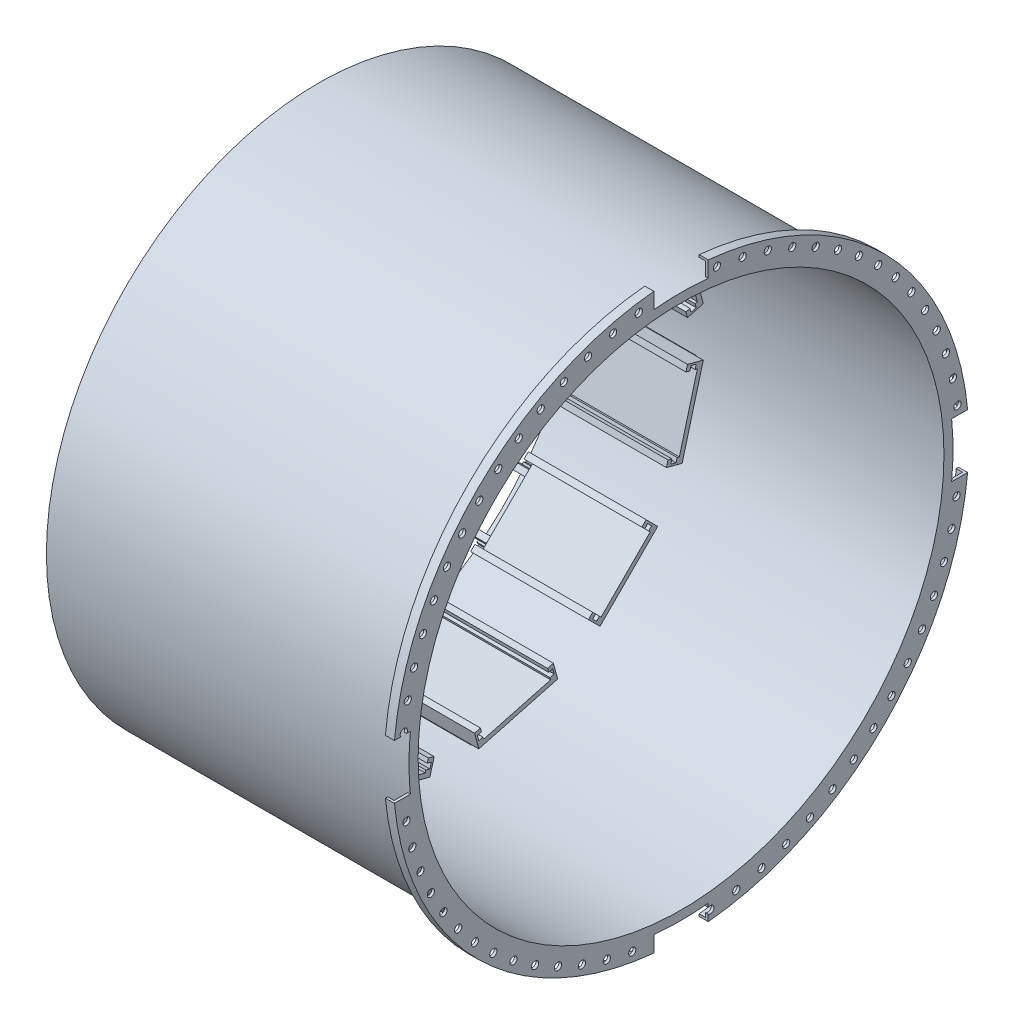
from build123d import *
from build123d.topology import SkipClean

# Parameters (mm, degrees)
CUT_EXTRUDE1_DEPTH    = 602.34224864
CIRPATTERN1_COUNT     = 4
BOSS_EXTRUDE1_DEPTH   = 130
BOSS_EXTRUDE2_DEPTH   = 130
BOSS_EXTRUDE2_2_DEPTH = 130
CIRPATTERN9_COUNT     = 12
SKETCH5_R             = 4
CUT_EXTRUDE2_DEPTH    = 130
CIRPATTERN10_COUNT    = 67


with BuildPart() as part:
    # Sketch1 → Revolve1 (revolve)
    with BuildSketch(Plane.XY, mode=Mode.PRIVATE) as revolve1_sk:
        Polygon((0, 290), (400, 290), (400, 317.5), (390, 317.5), (390, 315), (397, 315), (397, 300), (0, 300), align=None)
    revolve(revolve1_sk.sketch.rotate(Axis((-194.314172166, 0, 0), (1, 0, 0)), 90), axis=Axis((-194.314172166, 0, 0), (1, 0, 0)))

    # Sketch2 → Cut-Extrude1 (cut, through all)
    with SkipClean():  # the faces are left unmerged after this step: merging them gives an invalid solid
        with BuildSketch(Plane(origin=(0, 0, 0), x_dir=(0, 0, -1), z_dir=(1, 0, 0))):
            with BuildLine():
                Line((316.079499493, 30), (298.496231132, 30))
                ThreePointArc((298.496231132, 30), (300, 0), (298.496231132, -30))
                Line((298.496231132, -30), (316.079499493, -30))
                ThreePointArc((316.079499493, -30), (317.5, 0), (316.079499493, 30))
            make_face()
            with BuildLine():
                Line((-298.496231132, 30), (-316.079499493, 30))
                ThreePointArc((-316.079499493, 30), (-317.5, 0), (-316.079499493, -30))
                Line((-316.079499493, -30), (-298.496231132, -30))
                ThreePointArc((-298.496231132, -30), (-300, 0), (-298.496231132, 30))
            make_face()
        cut_extrude1 = extrude(amount=CUT_EXTRUDE1_DEPTH, mode=Mode.SUBTRACT)

    # CirPattern1: Cut-Extrude1 ×4 about axis
    with SkipClean():  # the faces are left unmerged after this step: merging them gives an invalid solid
        cirpattern1_axis = Axis((0, 0, 0), (-1, 0, 0))
        for i in range(1, CIRPATTERN1_COUNT):
            add(cut_extrude1.rotate(cirpattern1_axis, i * 360 / CIRPATTERN1_COUNT), mode=Mode.SUBTRACT)

    # Sketch5 → Cut-Extrude2 (cut)
    with SkipClean():  # the faces are left unmerged after this step: merging them gives an invalid solid
        with BuildSketch(Plane(origin=(400, 0, 0), x_dir=(0, 0, -1), z_dir=(1, 0, 0))):
            with Locations((217.435335215, 217.435335215)):
                Circle(SKETCH5_R)
        cut_extrude2 = extrude(amount=-CUT_EXTRUDE2_DEPTH, mode=Mode.SUBTRACT)

    # CirPattern10: Cut-Extrude2 ×67 about axis
    with SkipClean():  # the faces are left unmerged after this step: merging them gives an invalid solid
        cirpattern10_axis = Axis((0, 0, 0), (1, 0, 0))
        for i in range(1, CIRPATTERN10_COUNT):
            add(cut_extrude2.rotate(cirpattern10_axis, i * 360 / CIRPATTERN10_COUNT), mode=Mode.SUBTRACT)


with BuildPart() as body_2:
    # Sketch3 → Boss-Extrude1 (new body)
    with BuildSketch(Plane(origin=(20, 0, 0), x_dir=(0, 0, -1), z_dir=(1, 0, 0))):
        Polygon((-26.974606104, 274.537249226), (-113.90793047, 251.243535167), (-109.249187658, 233.856870294), (-102.832542394, 235.576205211), (-103.997228097, 239.922871429), (-108.482021709, 238.721174602), (-110.034935979, 244.51672956), (-105.550142368, 245.718426387), (-106.19718998, 248.133240952), (-32.097156143, 267.988285178), (-31.45010853, 265.573470613), (-26.965314918, 266.775167439), (-25.412400648, 260.979612481), (-29.897194259, 259.777915655), (-28.732508556, 255.431249437), (-22.315863292, 257.150584353), align=None)
    extrude(amount=BOSS_EXTRUDE1_DEPTH)


with BuildPart() as body_3:
    # Sketch4 → Boss-Extrude2 (new body)
    with BuildSketch(Plane(origin=(0, 0, 0), x_dir=(0, 0, -1), z_dir=(1, 0, 0))):
        Polygon((-38.357, 282.987347016), (-43, 282.987347016), (-43, 274.987347016), (-38.357, 274.987347016), (-38.357, 271.487347016), (-45, 271.487347016), (-45, 286.487347016), (-38.357, 286.487347016), align=None)
    extrude(amount=BOSS_EXTRUDE2_DEPTH)


with BuildPart() as body_4:
    # Sketch4 → Boss-Extrude2 2 (new body)
    with BuildSketch(Plane(origin=(0, 0, 0), x_dir=(0, 0, -1), z_dir=(1, 0, 0))):
        Polygon((-102.525537094, 254.293439321), (-96.77253034, 257.614939319), (-104.27253034, 270.605320376), (-110.025537095, 267.283820378), (-108.275537095, 264.252731465), (-104.254581145, 266.574231465), (-100.254581145, 259.646028235), (-104.275537095, 257.324528235), align=None)
    extrude(amount=BOSS_EXTRUDE2_2_DEPTH)


with BuildPart() as cirpattern9_1:
    # CirPattern9: pattern copy
    add(body_2.part.rotate(Axis((0, 0, 0), (1, 0, 0)), 1 * 360 / CIRPATTERN9_COUNT))


with BuildPart() as cirpattern9_2:
    # CirPattern9: pattern copy
    add(body_2.part.rotate(Axis((0, 0, 0), (1, 0, 0)), 2 * 360 / CIRPATTERN9_COUNT))


with BuildPart() as cirpattern9_3:
    # CirPattern9: pattern copy
    add(body_2.part.rotate(Axis((0, 0, 0), (1, 0, 0)), 3 * 360 / CIRPATTERN9_COUNT))


with BuildPart() as cirpattern9_4:
    # CirPattern9: pattern copy
    add(body_2.part.rotate(Axis((0, 0, 0), (1, 0, 0)), 4 * 360 / CIRPATTERN9_COUNT))


with BuildPart() as cirpattern9_5:
    # CirPattern9: pattern copy
    add(body_2.part.rotate(Axis((0, 0, 0), (1, 0, 0)), 5 * 360 / CIRPATTERN9_COUNT))


with BuildPart() as cirpattern9_6:
    # CirPattern9: pattern copy
    add(body_2.part.rotate(Axis((0, 0, 0), (1, 0, 0)), 6 * 360 / CIRPATTERN9_COUNT))


with BuildPart() as cirpattern9_7:
    # CirPattern9: pattern copy
    add(body_2.part.rotate(Axis((0, 0, 0), (1, 0, 0)), 7 * 360 / CIRPATTERN9_COUNT))


with BuildPart() as cirpattern9_8:
    # CirPattern9: pattern copy
    add(body_2.part.rotate(Axis((0, 0, 0), (1, 0, 0)), 8 * 360 / CIRPATTERN9_COUNT))


with BuildPart() as cirpattern9_9:
    # CirPattern9: pattern copy
    add(body_2.part.rotate(Axis((0, 0, 0), (1, 0, 0)), 9 * 360 / CIRPATTERN9_COUNT))


with BuildPart() as cirpattern9_10:
    # CirPattern9: pattern copy
    add(body_2.part.rotate(Axis((0, 0, 0), (1, 0, 0)), 10 * 360 / CIRPATTERN9_COUNT))


with BuildPart() as cirpattern9_11:
    # CirPattern9: pattern copy
    add(body_2.part.rotate(Axis((0, 0, 0), (1, 0, 0)), 11 * 360 / CIRPATTERN9_COUNT))


with BuildPart() as cirpattern9_12:
    # CirPattern9: pattern copy
    add(body_4.part.rotate(Axis((0, 0, 0), (1, 0, 0)), 1 * 360 / CIRPATTERN9_COUNT))


with BuildPart() as cirpattern9_13:
    # CirPattern9: pattern copy
    add(body_4.part.rotate(Axis((0, 0, 0), (1, 0, 0)), 2 * 360 / CIRPATTERN9_COUNT))


with BuildPart() as cirpattern9_14:
    # CirPattern9: pattern copy
    add(body_4.part.rotate(Axis((0, 0, 0), (1, 0, 0)), 3 * 360 / CIRPATTERN9_COUNT))


with BuildPart() as cirpattern9_15:
    # CirPattern9: pattern copy
    add(body_4.part.rotate(Axis((0, 0, 0), (1, 0, 0)), 4 * 360 / CIRPATTERN9_COUNT))


with BuildPart() as cirpattern9_16:
    # CirPattern9: pattern copy
    add(body_4.part.rotate(Axis((0, 0, 0), (1, 0, 0)), 5 * 360 / CIRPATTERN9_COUNT))


with BuildPart() as cirpattern9_17:
    # CirPattern9: pattern copy
    add(body_4.part.rotate(Axis((0, 0, 0), (1, 0, 0)), 6 * 360 / CIRPATTERN9_COUNT))


with BuildPart() as cirpattern9_18:
    # CirPattern9: pattern copy
    add(body_4.part.rotate(Axis((0, 0, 0), (1, 0, 0)), 7 * 360 / CIRPATTERN9_COUNT))


with BuildPart() as cirpattern9_19:
    # CirPattern9: pattern copy
    add(body_4.part.rotate(Axis((0, 0, 0), (1, 0, 0)), 8 * 360 / CIRPATTERN9_COUNT))


with BuildPart() as cirpattern9_20:
    # CirPattern9: pattern copy
    add(body_4.part.rotate(Axis((0, 0, 0), (1, 0, 0)), 9 * 360 / CIRPATTERN9_COUNT))


with BuildPart() as cirpattern9_21:
    # CirPattern9: pattern copy
    add(body_4.part.rotate(Axis((0, 0, 0), (1, 0, 0)), 10 * 360 / CIRPATTERN9_COUNT))


with BuildPart() as cirpattern9_22:
    # CirPattern9: pattern copy
    add(body_4.part.rotate(Axis((0, 0, 0), (1, 0, 0)), 11 * 360 / CIRPATTERN9_COUNT))


with BuildPart() as cirpattern9_23:
    # CirPattern9: pattern copy
    add(body_3.part.rotate(Axis((0, 0, 0), (1, 0, 0)), 1 * 360 / CIRPATTERN9_COUNT))


with BuildPart() as cirpattern9_24:
    # CirPattern9: pattern copy
    add(body_3.part.rotate(Axis((0, 0, 0), (1, 0, 0)), 2 * 360 / CIRPATTERN9_COUNT))


with BuildPart() as cirpattern9_25:
    # CirPattern9: pattern copy
    add(body_3.part.rotate(Axis((0, 0, 0), (1, 0, 0)), 3 * 360 / CIRPATTERN9_COUNT))


with BuildPart() as cirpattern9_26:
    # CirPattern9: pattern copy
    add(body_3.part.rotate(Axis((0, 0, 0), (1, 0, 0)), 4 * 360 / CIRPATTERN9_COUNT))


with BuildPart() as cirpattern9_27:
    # CirPattern9: pattern copy
    add(body_3.part.rotate(Axis((0, 0, 0), (1, 0, 0)), 5 * 360 / CIRPATTERN9_COUNT))


with BuildPart() as cirpattern9_28:
    # CirPattern9: pattern copy
    add(body_3.part.rotate(Axis((0, 0, 0), (1, 0, 0)), 6 * 360 / CIRPATTERN9_COUNT))


with BuildPart() as cirpattern9_29:
    # CirPattern9: pattern copy
    add(body_3.part.rotate(Axis((0, 0, 0), (1, 0, 0)), 7 * 360 / CIRPATTERN9_COUNT))


with BuildPart() as cirpattern9_30:
    # CirPattern9: pattern copy
    add(body_3.part.rotate(Axis((0, 0, 0), (1, 0, 0)), 8 * 360 / CIRPATTERN9_COUNT))


with BuildPart() as cirpattern9_31:
    # CirPattern9: pattern copy
    add(body_3.part.rotate(Axis((0, 0, 0), (1, 0, 0)), 9 * 360 / CIRPATTERN9_COUNT))


with BuildPart() as cirpattern9_32:
    # CirPattern9: pattern copy
    add(body_3.part.rotate(Axis((0, 0, 0), (1, 0, 0)), 10 * 360 / CIRPATTERN9_COUNT))


with BuildPart() as cirpattern9_33:
    # CirPattern9: pattern copy
    add(body_3.part.rotate(Axis((0, 0, 0), (1, 0, 0)), 11 * 360 / CIRPATTERN9_COUNT))


solid = Compound([part.part, body_2.part, body_3.part, body_4.part, cirpattern9_1.part, cirpattern9_2.part, cirpattern9_3.part, cirpattern9_4.part, cirpattern9_5.part, cirpattern9_6.part, cirpattern9_7.part, cirpattern9_8.part, cirpattern9_9.part, cirpattern9_10.part, cirpattern9_11.part, cirpattern9_12.part, cirpattern9_13.part, cirpattern9_14.part, cirpattern9_15.part, cirpattern9_16.part, cirpattern9_17.part, cirpattern9_18.part, cirpattern9_19.part, cirpattern9_20.part, cirpattern9_21.part, cirpattern9_22.part, cirpattern9_23.part, cirpattern9_24.part, cirpattern9_25.part, cirpattern9_26.part, cirpattern9_27.part, cirpattern9_28.part, cirpattern9_29.part, cirpattern9_30.part, cirpattern9_31.part, cirpattern9_32.part, cirpattern9_33.part])
